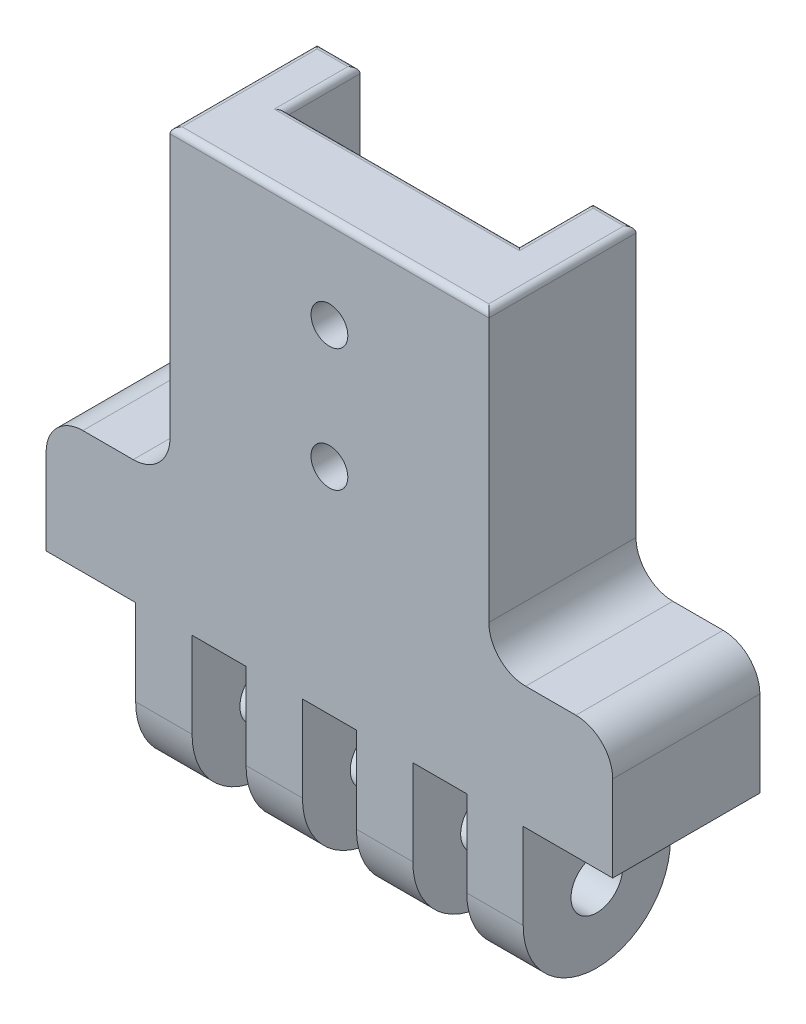
from build123d import *

# Parameters (mm, degrees)
SKETCH1_W           = 46.2
SKETCH1_H           = 12
BOSS_EXTRUDE1_DEPTH = 10
SKETCH2_W           = 4.6
SKETCH2_H           = 12
BOSS_EXTRUDE2_DEPTH = 7
SKETCH8_R           = 6
BOSS_EXTRUDE3_DEPTH = 4.6
LPATTERN1_COUNT     = 4
LPATTERN1_PITCH     = 9
SKETCH4_R           = 2.1
CUT_EXTRUDE1_DEPTH  = 39.9
SKETCH10_W          = 26
SKETCH10_H          = 12
BOSS_EXTRUDE4_DEPTH = 25
SKETCH11_W          = 19
SKETCH11_H          = 6
CUT_EXTRUDE2_DEPTH  = 25
FILLET1_R           = 3
FILLET2_R           = 0.5
SKETCH12_R          = 1.5
CUT_EXTRUDE3_DEPTH  = 10


with BuildPart() as part:
    # Sketch1 → Boss-Extrude1 (new body)
    with BuildSketch(Plane(origin=(0, 0, 0), x_dir=(1, 0, 0), z_dir=(0, 1, 0))):
        Rectangle(SKETCH1_W, SKETCH1_H)
    extrude(amount=BOSS_EXTRUDE1_DEPTH)

    # Sketch2 → Boss-Extrude2 (add)
    with BuildSketch(Plane.XZ):
        with Locations((13.5, 0)):
            Rectangle(SKETCH2_W, SKETCH2_H)
    boss_extrude2 = extrude(amount=BOSS_EXTRUDE2_DEPTH)

    # Sketch8 → Boss-Extrude3 (add)
    with BuildSketch(Plane(origin=(15.8, 0, 0), x_dir=(0, 0, -1), z_dir=(1, 0, 0))):
        with Locations((0, -7)):
            Circle(SKETCH8_R)
    boss_extrude3 = extrude(amount=-BOSS_EXTRUDE3_DEPTH)

    # LPattern1: Boss-Extrude2, Boss-Extrude3 ×4
    with Locations(*[(-i * LPATTERN1_PITCH, 0, 0) for i in range(1, LPATTERN1_COUNT)]):
        add(boss_extrude2)
        add(boss_extrude3)

    # Sketch4 → Cut-Extrude1 (cut, through all)
    with BuildSketch(Plane(origin=(15.8, 0, 0), x_dir=(0, 0, -1), z_dir=(1, 0, 0))):
        with Locations((0, -7)):
            Circle(SKETCH4_R)
    extrude(amount=-CUT_EXTRUDE1_DEPTH, mode=Mode.SUBTRACT)

    # Sketch10 → Boss-Extrude4 (add)
    with BuildSketch(Plane(origin=(0, 10, 0), x_dir=(1, 0, 0), z_dir=(0, 1, 0))):
        Rectangle(SKETCH10_W, SKETCH10_H)
    extrude(amount=BOSS_EXTRUDE4_DEPTH)

    # Sketch11 → Cut-Extrude2 (cut)
    with BuildSketch(Plane(origin=(0, 35, 0), x_dir=(1, 0, 0), z_dir=(0, 1, 0))):
        with Locations((0, 3)):
            Rectangle(SKETCH11_W, SKETCH11_H)
    extrude(amount=-CUT_EXTRUDE2_DEPTH, mode=Mode.SUBTRACT)

    # Fillet1
    fillet1_edges = [part.edges().sort_by_distance(p)[0] for p in [
        (-13, 10, 0),
        (13, 10, 0),
        (23.1, 10, 0),
        (-23.1, 10, 0),
    ]]
    fillet(fillet1_edges, radius=FILLET1_R)

    # Fillet2
    fillet2_edges = [part.edges().sort_by_distance(p)[0] for p in [
        (-13, 35, 0),
        (0, 35, 6),
        (13, 35, 0),
        (11.25, 35, -6),
        (-11.25, 35, -6),
        (-9.5, 35, -3),
        (0, 35, 0),
        (9.5, 35, -3),
    ]]
    fillet(fillet2_edges, radius=FILLET2_R)

    # Sketch12 → Cut-Extrude3 (cut, symmetric)
    with BuildSketch(Plane.XY):
        with Locations((0, 17.5)):
            Circle(SKETCH12_R)
        with Locations((0, 27.5)):
            Circle(SKETCH12_R)
    extrude(amount=CUT_EXTRUDE3_DEPTH, both=True, mode=Mode.SUBTRACT)


solid = part.part
